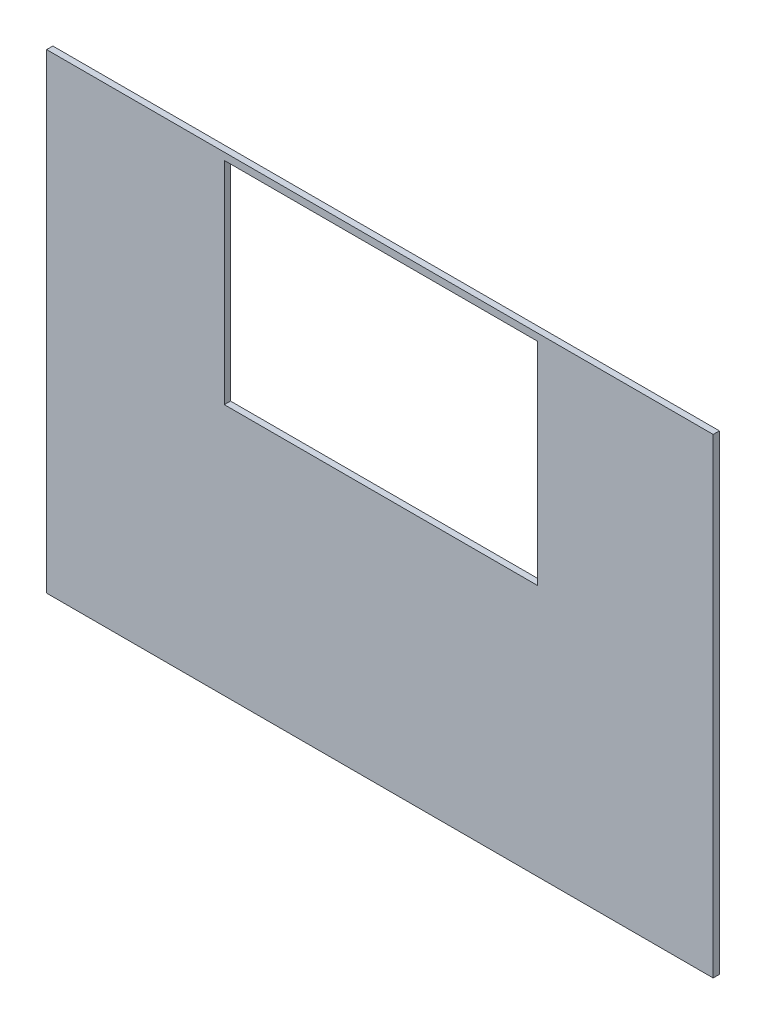
from build123d import *

# Parameters (mm, degrees)
SKETCH1_W           = 681.08
SKETCH1_H           = 481.00261168
BOSS_EXTRUDE1_DEPTH = 6.35
SKETCH2_W           = 319.846223413
SKETCH2_H           = 216.113551909
CUT_EXTRUDE1_DEPTH  = 10


with BuildPart() as part:
    # Sketch1 → Boss-Extrude1 (new body)
    with BuildSketch(Plane.XY):
        with Locations((340.54, -240.50130584)):
            Rectangle(SKETCH1_W, SKETCH1_H)
    extrude(amount=BOSS_EXTRUDE1_DEPTH)

    # Sketch2 → Cut-Extrude1 (cut)
    with BuildSketch(Plane(origin=(0, 0, 0), x_dir=(-1, 0, 0), z_dir=(0, 0, -1))):
        with Locations((-341.464956121, -115.352129436)):
            Rectangle(SKETCH2_W, SKETCH2_H)
    extrude(amount=-CUT_EXTRUDE1_DEPTH, mode=Mode.SUBTRACT)


solid = part.part
